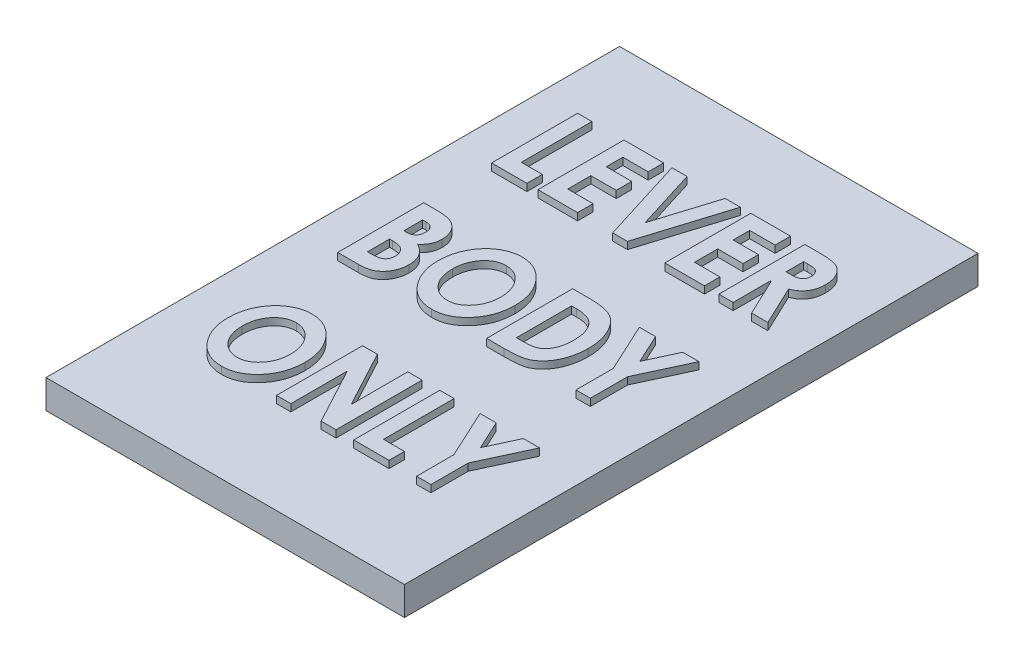
from build123d import *

# Parameters (mm, degrees)
SKETCH1_W           = 19.4
SKETCH1_H           = 34.4
BOSS_EXTRUDE1_DEPTH = 2
SKETCH2_W           = 25
SKETCH2_H           = 40
BOSS_EXTRUDE2_DEPTH = 2
BOSS_EXTRUDE3_DEPTH = 0.5


with BuildPart() as part:
    # Sketch1 → Boss-Extrude1 (new body)
    with BuildSketch(Plane(origin=(0, 0, 0), x_dir=(1, 0, 0), z_dir=(0, 1, 0))):
        Rectangle(SKETCH1_W, SKETCH1_H)
    extrude(amount=BOSS_EXTRUDE1_DEPTH)

    # Sketch2 → Boss-Extrude2 (add)
    with BuildSketch(Plane(origin=(0, 2, 0), x_dir=(1, 0, 0), z_dir=(0, 1, 0))):
        Rectangle(SKETCH2_W, SKETCH2_H)
    extrude(amount=BOSS_EXTRUDE2_DEPTH)

    # Sketch3 → Boss-Extrude3 (add)
    with BuildSketch(Plane(origin=(0, 4, 0), x_dir=(1, 0, 0), z_dir=(0, 1, 0))):
        Polygon((-9.423076923, 14), (-8.423076923, 14), (-8.423076923, 9.076923077), (-6.961538462, 9.076923077), (-6.961538462, 8), (-9.423076923, 8), align=None)
        Polygon((-6.192307692, 14), (-3.423076923, 14), (-3.423076923, 12.923076923), (-5.192307692, 12.923076923), (-5.192307692, 11.769230769), (-3.423076923, 11.769230769), (-3.423076923, 10.692307692), (-5.192307692, 10.692307692), (-5.192307692, 9.076923077), (-3.423076923, 9.076923077), (-3.423076923, 8), (-6.192307692, 8), align=None)
        Polygon((-2.846153846, 14), (-1.788461538, 14), (-0.461538462, 9.737980769), (0.867788462, 14), (1.923076923, 14), (0.051682692, 8), (-0.977163462, 8), align=None)
        Polygon((2.653846154, 14), (5.423076923, 14), (5.423076923, 12.923076923), (3.653846154, 12.923076923), (3.653846154, 11.769230769), (5.423076923, 11.769230769), (5.423076923, 10.692307692), (3.653846154, 10.692307692), (3.653846154, 9.076923077), (5.423076923, 9.076923077), (5.423076923, 8), (2.653846154, 8), align=None)
        with BuildLine():
            Line((6.423076923, 14), (7.495192308, 14))
            add(Edge.make_bspline(
                [(7.495192308, 14), (7.565716082, 13.999692793), (7.702010779, 13.999099082), (7.898391471, 13.990259019), (8.079272988, 13.977728257), (8.244156273, 13.958758313), (8.393014185, 13.933838236), (8.526193833, 13.903624533), (8.644139743, 13.87011321), (8.779050299, 13.815187629), (8.930257846, 13.729159202), (9.092102694, 13.597787753), (9.233816486, 13.436238489), (9.355507645, 13.248692243), (9.455996707, 13.038283275), (9.526259048, 12.806550176), (9.56898116, 12.556866273), (9.574225501, 12.384390756), (9.576923077, 12.295673077)],
                knots=[0, 0, 0, 0, 0.000211552, 0.000408847, 0.00058962, 0.000755402, 0.000906563, 0.001042146, 0.001164983, 0.001273902, 0.001478441, 0.001684363, 0.001896369, 0.002120391, 0.002353186, 0.002593456, 0.002844601, 0.003110617, 0.003110617, 0.003110617, 0.003110617], degree=3))
            add(Edge.make_bspline(
                [(9.576923077, 12.295673077), (9.57634034, 12.248372382), (9.575197559, 12.155612924), (9.562997288, 12.019467998), (9.542424057, 11.889473187), (9.514918602, 11.764865894), (9.479415699, 11.64605475), (9.433945253, 11.533657974), (9.383200458, 11.42639336), (9.322007668, 11.325942603), (9.254082633, 11.231148047), (9.177195351, 11.142737763), (9.093581116, 11.059422992), (8.999749925, 10.983791093), (8.898931748, 10.912490949), (8.789272857, 10.848096085), (8.672313049, 10.788408867), (8.590015205, 10.755003739), (8.548076923, 10.737980769)],
                knots=[0, 0, 0, 0, 0.000141873, 0.000278221, 0.000409627, 0.000536474, 0.000660808, 0.000781108, 0.00089991, 0.001016373, 0.00113346, 0.001249357, 0.001367494, 0.001487072, 0.001610449, 0.001737632, 0.001868249, 0.002003976, 0.002003976, 0.002003976, 0.002003976], degree=3))
            Line((8.548076923, 10.737980769), (9.846153846, 8))
            Line((9.846153846, 8), (8.710336538, 8))
            Line((8.710336538, 8), (7.469951923, 10.615384615))
            Line((7.469951923, 10.615384615), (7.423076923, 10.615384615))
            Line((7.423076923, 10.615384615), (7.423076923, 8))
            Line((7.423076923, 8), (6.423076923, 8))
            Line((6.423076923, 8), (6.423076923, 14))
        make_face()
        with BuildLine():
            Line((7.423076923, 11.692307692), (7.737980769, 11.692307692))
            add(Edge.make_bspline(
                [(7.737980769, 11.692307692), (7.776444427, 11.692888957), (7.850215642, 11.69400379), (7.95624872, 11.699097626), (8.052470782, 11.711523783), (8.139483597, 11.727213836), (8.218081269, 11.745218745), (8.286524629, 11.771018343), (8.346488021, 11.799230102), (8.41266021, 11.84465353), (8.481983468, 11.916603886), (8.538731233, 12.028063417), (8.572097584, 12.161949108), (8.575245837, 12.258603368), (8.576923077, 12.310096154)],
                knots=[0, 0, 0, 0, 0.00011541, 0.000221349, 0.000318252, 0.000406189, 0.000486646, 0.000559658, 0.000625237, 0.000684911, 0.000799674, 0.000920645, 0.001055908, 0.001210134, 0.001210134, 0.001210134, 0.001210134], degree=3))
            add(Edge.make_bspline(
                [(8.576923077, 12.310096154), (8.575743875, 12.341827369), (8.573442756, 12.403748342), (8.556284171, 12.493096474), (8.528812603, 12.576443972), (8.488732703, 12.651576163), (8.440824607, 12.719628017), (8.38404366, 12.777722916), (8.3195226, 12.825220132), (8.244050024, 12.863789384), (8.148509814, 12.891389305), (8.025928454, 12.910559882), (7.87239739, 12.921700941), (7.759634934, 12.92259225), (7.698317308, 12.923076923)],
                knots=[0, 0, 0, 0, 9.5142e-05, 0.000185662, 0.000271941, 0.000357422, 0.000440136, 0.00052088, 0.00059997, 0.000679524, 0.000773812, 0.000896914, 0.001051229, 0.001235158, 0.001235158, 0.001235158, 0.001235158], degree=3))
            Line((7.698317308, 12.923076923), (7.423076923, 12.923076923))
            Line((7.423076923, 12.923076923), (7.423076923, 11.692307692))
        make_face(mode=Mode.SUBTRACT)
        with BuildLine():
            Line((-9.384615385, -2.769230769), (-9.384615385, 3.230769231))
            Line((-9.384615385, 3.230769231), (-8.575721154, 3.230769231))
            add(Edge.make_bspline(
                [(-8.575721154, 3.230769231), (-8.519223397, 3.230779244), (-8.409797524, 3.230798639), (-8.251527984, 3.224137387), (-8.1048841, 3.21575209), (-7.970014332, 3.206007352), (-7.847487459, 3.189714384), (-7.736666137, 3.172301881), (-7.637370877, 3.151126425), (-7.576018233, 3.13259888), (-7.546875, 3.123798077)],
                knots=[0, 0, 0, 0, 0.000169475, 0.000328243, 0.000475119, 0.000610168, 0.000733756, 0.000845793, 0.000946697, 0.001037996, 0.001037996, 0.001037996, 0.001037996], degree=3))
            add(Edge.make_bspline(
                [(-7.546875, 3.123798077), (-7.50895312, 3.111263932), (-7.433889188, 3.086453395), (-7.326939058, 3.037596266), (-7.225590471, 2.982344728), (-7.129952113, 2.91969153), (-7.040650895, 2.848451795), (-6.957806657, 2.76882825), (-6.880642941, 2.682016213), (-6.809888719, 2.588393857), (-6.746163543, 2.488843349), (-6.691041525, 2.384164115), (-6.643730514, 2.27538287), (-6.605222336, 2.161999231), (-6.575442917, 2.044201303), (-6.55329253, 1.922185523), (-6.541792023, 1.795492904), (-6.539584043, 1.709554987), (-6.538461538, 1.665865385)],
                knots=[0, 0, 0, 0, 0.000119741, 0.000237019, 0.000352128, 0.000465803, 0.000579555, 0.000694318, 0.000810103, 0.000927652, 0.001046015, 0.0011643, 0.001282192, 0.00140154, 0.001523101, 0.001646408, 0.001773181, 0.001904279, 0.001904279, 0.001904279, 0.001904279], degree=3))
            add(Edge.make_bspline(
                [(-6.538461538, 1.665865385), (-6.54014369, 1.609696432), (-6.543451703, 1.499238068), (-6.567568843, 1.337455146), (-6.608999868, 1.183701436), (-6.665359697, 1.036786187), (-6.741253748, 0.895929761), (-6.83855043, 0.761798645), (-6.954664737, 0.630153137), (-7.044734275, 0.550721859), (-7.091346154, 0.509615385)],
                knots=[0, 0, 0, 0, 0.000168479, 0.000331321, 0.000489341, 0.00064536, 0.000802389, 0.000967818, 0.001141495, 0.001327778, 0.001327778, 0.001327778, 0.001327778], degree=3))
            add(Edge.make_bspline(
                [(-7.091346154, 0.509615385), (-7.051817001, 0.488039316), (-6.974329897, 0.445744783), (-6.864843951, 0.375730957), (-6.763143382, 0.30209537), (-6.669513415, 0.224658462), (-6.585120992, 0.141952308), (-6.50742828, 0.056843737), (-6.439049013, -0.033518199), (-6.35862584, -0.159121332), (-6.275357097, -0.328043204), (-6.204521409, -0.547378676), (-6.161764955, -0.784402781), (-6.156537908, -0.948135201), (-6.153846154, -1.032451923)],
                knots=[0, 0, 0, 0, 0.000135071, 0.000264773, 0.000389547, 0.000511582, 0.000628879, 0.000743768, 0.000856992, 0.00096835, 0.001190884, 0.001419698, 0.001657818, 0.001910634, 0.001910634, 0.001910634, 0.001910634], degree=3))
            add(Edge.make_bspline(
                [(-6.153846154, -1.032451923), (-6.156594668, -1.114374148), (-6.162007816, -1.275718466), (-6.205603009, -1.511862417), (-6.274976299, -1.737619757), (-6.373689267, -1.948466839), (-6.492493121, -2.141473397), (-6.630267328, -2.310195479), (-6.784600771, -2.453005097), (-6.927536116, -2.550326258), (-7.051341578, -2.615741234), (-7.154037336, -2.655032792), (-7.263266757, -2.692615296), (-7.382457851, -2.718769322), (-7.508966525, -2.742305299), (-7.644750132, -2.757242352), (-7.788316244, -2.767039015), (-7.887001552, -2.768488864), (-7.9375, -2.769230769)],
                knots=[0, 0, 0, 0, 0.000245616, 0.000483736, 0.000717911, 0.000952372, 0.001180171, 0.00139624, 0.001603786, 0.001808809, 0.001913099, 0.002023133, 0.002138298, 0.002259287, 0.002388721, 0.00252424, 0.002668791, 0.002820277, 0.002820277, 0.002820277, 0.002820277], degree=3))
            Line((-7.9375, -2.769230769), (-9.384615385, -2.769230769))
        make_face()
        with BuildLine():
            Line((-8.384615385, 2.153846154), (-8.384615385, 0.846153846))
            Line((-8.384615385, 0.846153846), (-8.1875, 0.846153846))
            add(Edge.make_bspline(
                [(-8.1875, 0.846153846), (-8.135970161, 0.847719424), (-8.038368132, 0.850684766), (-7.902730464, 0.886293702), (-7.786785678, 0.94260981), (-7.694575497, 1.024731845), (-7.624115694, 1.125730918), (-7.573233379, 1.24335541), (-7.543074265, 1.377507101), (-7.540043851, 1.472194289), (-7.538461538, 1.521634615)],
                knots=[0, 0, 0, 0, 0.000154226, 0.000292118, 0.00041736, 0.000537438, 0.000658158, 0.000784102, 0.000919685, 0.001067834, 0.001067834, 0.001067834, 0.001067834], degree=3))
            add(Edge.make_bspline(
                [(-7.538461538, 1.521634615), (-7.540052556, 1.56789856), (-7.543089778, 1.656215571), (-7.57299262, 1.780890624), (-7.619188768, 1.891842809), (-7.687807945, 1.985656031), (-7.775113175, 2.062884387), (-7.883771389, 2.117442112), (-8.012347939, 2.148305748), (-8.103989639, 2.151924748), (-8.152644231, 2.153846154)],
                knots=[0, 0, 0, 0, 0.000138555, 0.000264499, 0.000382392, 0.000496827, 0.000610121, 0.000728917, 0.000857764, 0.001003598, 0.001003598, 0.001003598, 0.001003598], degree=3))
            Line((-8.152644231, 2.153846154), (-8.384615385, 2.153846154))
        make_face(mode=Mode.SUBTRACT)
        with BuildLine():
            Line((-8.384615385, -0.153846154), (-8.384615385, -1.692307692))
            Line((-8.384615385, -1.692307692), (-8.149038462, -1.692307692))
            add(Edge.make_bspline(
                [(-8.149038462, -1.692307692), (-8.102152584, -1.691956339), (-8.011902957, -1.691280027), (-7.882664911, -1.683138923), (-7.765564262, -1.668551254), (-7.660521927, -1.650061426), (-7.567112784, -1.624886702), (-7.485660793, -1.594120202), (-7.415518355, -1.55832623), (-7.340143284, -1.501796888), (-7.264139712, -1.415306015), (-7.198036828, -1.291730914), (-7.161056072, -1.146693885), (-7.156332131, -1.044280006), (-7.153846154, -0.990384615)],
                knots=[0, 0, 0, 0, 0.000140646, 0.000270726, 0.000388201, 0.000494522, 0.00059045, 0.000677951, 0.000755371, 0.000825804, 0.000959455, 0.001097111, 0.001242588, 0.001404188, 0.001404188, 0.001404188, 0.001404188], degree=3))
            add(Edge.make_bspline(
                [(-7.153846154, -0.990384615), (-7.154522301, -0.95870714), (-7.155836009, -0.897159971), (-7.166501756, -0.807286972), (-7.186032168, -0.722879066), (-7.212126436, -0.64337779), (-7.246194974, -0.56930711), (-7.287286468, -0.500406649), (-7.335682454, -0.435985363), (-7.392431253, -0.376933657), (-7.457758736, -0.323347643), (-7.533147443, -0.277703731), (-7.618221654, -0.238872555), (-7.713680672, -0.208579186), (-7.818294802, -0.182607853), (-7.933141109, -0.167110862), (-8.057456704, -0.15554585), (-8.143798234, -0.154427681), (-8.188701923, -0.153846154)],
                knots=[0, 0, 0, 0, 9.502e-05, 0.000184618, 0.000270923, 0.00035454, 0.000435213, 0.000514984, 0.000594793, 0.000676399, 0.000760121, 0.000847523, 0.000940032, 0.001039994, 0.001147565, 0.001262981, 0.001387251, 0.001521914, 0.001521914, 0.001521914, 0.001521914], degree=3))
            Line((-8.188701923, -0.153846154), (-8.384615385, -0.153846154))
        make_face(mode=Mode.SUBTRACT)
        with BuildLine():
            add(Edge.make_bspline(
                [(-2.681490385, 3.384615385), (-2.591164255, 3.381950448), (-2.413053702, 3.376695563), (-2.150935296, 3.331641838), (-1.898422683, 3.259621782), (-1.655432938, 3.158133184), (-1.423023311, 3.026463346), (-1.199831022, 2.867405077), (-0.987681743, 2.677594102), (-0.786611524, 2.463531782), (-0.602747581, 2.228210672), (-0.440912701, 1.977818944), (-0.304958626, 1.71427333), (-0.191677454, 1.439295165), (-0.107377357, 1.150012365), (-0.044505324, 0.849166271), (-0.006361322, 0.535035636), (-0.002145075, 0.321420219), (0, 0.212740385)],
                knots=[0, 0, 0, 0, 0.000270817, 0.000534013, 0.000795362, 0.001057196, 0.001321969, 0.001595123, 0.001877797, 0.002174555, 0.002475096, 0.002772484, 0.003067612, 0.003363571, 0.003663238, 0.00397015, 0.004284863, 0.004610806, 0.004610806, 0.004610806, 0.004610806], degree=3))
            add(Edge.make_bspline(
                [(0, 0.212740385), (-0.002088915, 0.105247644), (-0.006201855, -0.106398751), (-0.045221542, -0.416976174), (-0.104295057, -0.715660813), (-0.189739524, -1.001531272), (-0.301208269, -1.27440565), (-0.435916328, -1.535008127), (-0.595885479, -1.78241769), (-0.776594377, -2.015165241), (-0.976141215, -2.226057211), (-1.186616561, -2.413170521), (-1.409169908, -2.569987921), (-1.641058163, -2.700240621), (-1.884402526, -2.800689766), (-2.138549561, -2.87168519), (-2.403181874, -2.914722806), (-2.583173366, -2.920269419), (-2.674278846, -2.923076923)],
                knots=[0, 0, 0, 0, 0.00032234, 0.000634666, 0.000937563, 0.001234926, 0.001528205, 0.001820646, 0.002113701, 0.002410868, 0.002703353, 0.002983535, 0.003254317, 0.003518502, 0.003779876, 0.004042052, 0.004308614, 0.004581831, 0.004581831, 0.004581831, 0.004581831], degree=3))
            add(Edge.make_bspline(
                [(-2.674278846, -2.923076923), (-2.769832133, -2.920581663), (-2.957607937, -2.915678122), (-3.232216693, -2.868746866), (-3.495578733, -2.798016906), (-3.744950499, -2.692976314), (-3.983023867, -2.56133545), (-4.207324744, -2.398616705), (-4.419629753, -2.207360087), (-4.61740351, -1.990106351), (-4.795603935, -1.752072268), (-4.954734891, -1.501842605), (-5.086628681, -1.23881097), (-5.195469629, -0.965337827), (-5.281246432, -0.681596897), (-5.340894687, -0.386229456), (-5.377967896, -0.08027681), (-5.382378521, 0.127697972), (-5.384615385, 0.233173077)],
                knots=[0, 0, 0, 0, 0.000286421, 0.000562858, 0.000833462, 0.001102878, 0.001372433, 0.001647964, 0.001932239, 0.002228312, 0.002527832, 0.002823283, 0.003116769, 0.00340915, 0.003705363, 0.004004726, 0.004312136, 0.004628471, 0.004628471, 0.004628471, 0.004628471], degree=3))
            add(Edge.make_bspline(
                [(-5.384615385, 0.233173077), (-5.383397255, 0.30412125), (-5.380978251, 0.445012578), (-5.363559938, 0.654028624), (-5.336563491, 0.858839828), (-5.296284183, 1.058936932), (-5.246020956, 1.254824212), (-5.184646307, 1.446827975), (-5.111243652, 1.634154789), (-5.026883646, 1.816481702), (-4.934554703, 1.992797911), (-4.829887388, 2.158617406), (-4.7198769, 2.316739867), (-4.600523611, 2.464855439), (-4.472485383, 2.603826429), (-4.336040378, 2.733242875), (-4.190674232, 2.852797057), (-4.038645393, 2.962905002), (-3.881121848, 3.062968203), (-3.717969059, 3.147598125), (-3.553359515, 3.222401666), (-3.38430353, 3.280245886), (-3.213302631, 3.328610358), (-3.038508742, 3.359704127), (-2.861149416, 3.381937947), (-2.741657833, 3.383718716), (-2.681490385, 3.384615385)],
                knots=[0, 0, 0, 0, 0.000212825, 0.000422636, 0.000628824, 0.000832248, 0.00103456, 0.001235256, 0.001436581, 0.001637716, 0.00183773, 0.002033168, 0.002225569, 0.002415344, 0.002603324, 0.002792069, 0.002979048, 0.003167535, 0.003354947, 0.003538278, 0.003718527, 0.003896805, 0.004073798, 0.004251072, 0.004428933, 0.004609321, 0.004609321, 0.004609321, 0.004609321], degree=3))
        make_face()
        with BuildLine():
            add(Edge.make_bspline(
                [(-2.695913462, 2.307692308), (-2.75452499, 2.305834514), (-2.870007443, 2.302174097), (-3.039283894, 2.273466331), (-3.20151597, 2.228568585), (-3.355706089, 2.161807002), (-3.503771585, 2.079355677), (-3.64442309, 1.977129802), (-3.776716275, 1.855993105), (-3.900931391, 1.718260122), (-4.014467278, 1.566873194), (-4.113601374, 1.403295329), (-4.197576612, 1.23024597), (-4.266814261, 1.047323784), (-4.319241261, 0.853976084), (-4.357515284, 0.651074609), (-4.380988101, 0.438052793), (-4.383388449, 0.2929296), (-4.384615385, 0.21875)],
                knots=[0, 0, 0, 0, 0.000175744, 0.000346269, 0.000513677, 0.000679547, 0.000849057, 0.001021196, 0.001199875, 0.001386235, 0.00157686, 0.001766707, 0.00195915, 0.00215314, 0.002352587, 0.002559321, 0.002772089, 0.002994562, 0.002994562, 0.002994562, 0.002994562], degree=3))
            add(Edge.make_bspline(
                [(-4.384615385, 0.21875), (-4.382848022, 0.136530174), (-4.379388111, -0.024428948), (-4.350074025, -0.258969355), (-4.30251585, -0.480508231), (-4.234317519, -0.688288922), (-4.150087364, -0.88446937), (-4.042530646, -1.065108406), (-3.919200163, -1.234959431), (-3.821053231, -1.334496708), (-3.771634615, -1.384615385)],
                knots=[0, 0, 0, 0, 0.000246582, 0.000482725, 0.00070787, 0.000925282, 0.001137873, 0.001346897, 0.001554833, 0.001765715, 0.001765715, 0.001765715, 0.001765715], degree=3))
            add(Edge.make_bspline(
                [(-3.771634615, -1.384615385), (-3.731837841, -1.421463544), (-3.653562156, -1.493939642), (-3.526612245, -1.587353146), (-3.396276722, -1.667705174), (-3.260952816, -1.732953736), (-3.121161001, -1.783563638), (-2.97703852, -1.819784526), (-2.828822436, -1.842065954), (-2.728442066, -1.844784584), (-2.677884615, -1.846153846)],
                knots=[0, 0, 0, 0, 0.000162598, 0.000319811, 0.000471938, 0.000621383, 0.000769664, 0.000917168, 0.001066579, 0.001218193, 0.001218193, 0.001218193, 0.001218193], degree=3))
            add(Edge.make_bspline(
                [(-2.677884615, -1.846153846), (-2.620885262, -1.844245159), (-2.508212271, -1.840472179), (-2.342268753, -1.812214094), (-2.183016444, -1.765133757), (-2.029993616, -1.69961398), (-1.883813441, -1.615024297), (-1.745177404, -1.510334429), (-1.612583561, -1.388162178), (-1.487284322, -1.249529618), (-1.372515629, -1.096951333), (-1.273069628, -0.933153092), (-1.187772272, -0.761321431), (-1.119851565, -0.5802274), (-1.065042059, -0.390695041), (-1.02731772, -0.192322527), (-1.003616847, 0.014644912), (-1.001221641, 0.155382335), (-1, 0.227163462)],
                knots=[0, 0, 0, 0, 0.000170944, 0.000337912, 0.000503345, 0.00066811, 0.000836125, 0.001008722, 0.001188211, 0.001376269, 0.001568577, 0.001760075, 0.001950359, 0.002143225, 0.002339526, 0.002541538, 0.002748332, 0.002963597, 0.002963597, 0.002963597, 0.002963597], degree=3))
            add(Edge.make_bspline(
                [(-1, 0.227163462), (-1.001105024, 0.298556519), (-1.003278245, 0.438963358), (-1.028748392, 0.644997304), (-1.0664444, 0.842942952), (-1.120638738, 1.032478462), (-1.190901893, 1.213154832), (-1.274756083, 1.386500691), (-1.376722309, 1.549839608), (-1.491105558, 1.704321996), (-1.617047299, 1.844833153), (-1.751263235, 1.96814392), (-1.890660109, 2.074335652), (-2.03900953, 2.158822306), (-2.19380645, 2.225419685), (-2.355330999, 2.274048129), (-2.523872091, 2.301928637), (-2.638121272, 2.305756174), (-2.695913462, 2.307692308)],
                knots=[0, 0, 0, 0, 0.000214064, 0.000420994, 0.000621826, 0.000818127, 0.001011423, 0.001202786, 0.001394913, 0.001588184, 0.001778832, 0.001960019, 0.002134298, 0.002303355, 0.002470803, 0.002638883, 0.002808222, 0.002981566, 0.002981566, 0.002981566, 0.002981566], degree=3))
        make_face(mode=Mode.SUBTRACT)
        with BuildLine():
            Line((1, 3.230769231), (2.181490385, 3.230769231))
            add(Edge.make_bspline(
                [(2.181490385, 3.230769231), (2.273662624, 3.230018527), (2.452140179, 3.228564904), (2.710393115, 3.212571589), (2.950653338, 3.187617422), (3.172775389, 3.153620317), (3.376600674, 3.108521827), (3.561638159, 3.05160638), (3.728999806, 2.986467723), (3.880031096, 2.909529867), (4.017349051, 2.819759858), (4.147970469, 2.719779993), (4.271681185, 2.606635016), (4.388706925, 2.480272395), (4.500930858, 2.342416004), (4.604733453, 2.18979083), (4.704961156, 2.026743274), (4.797156201, 1.851227775), (4.880823071, 1.665888942), (4.954755281, 1.471876669), (5.015462019, 1.269605012), (5.066095374, 1.059771897), (5.105913195, 0.842333654), (5.132906697, 0.617126484), (5.150311385, 0.384488016), (5.152654886, 0.226794608), (5.153846154, 0.146634615)],
                knots=[0, 0, 0, 0, 0.000276484, 0.00053537, 0.00077588, 0.001000951, 0.001209148, 0.001401523, 0.001581194, 0.001747294, 0.001908987, 0.002072701, 0.002240303, 0.002411234, 0.002588997, 0.002773032, 0.002964531, 0.003162921, 0.003367336, 0.00357427, 0.003785292, 0.004000433, 0.004221567, 0.00444802, 0.004680601, 0.004921061, 0.004921061, 0.004921061, 0.004921061], degree=3))
            add(Edge.make_bspline(
                [(5.153846154, 0.146634615), (5.151858115, 0.0335282), (5.14794752, -0.188959076), (5.107595895, -0.515181604), (5.046576806, -0.828522164), (4.956701758, -1.12497884), (4.849292817, -1.403902526), (4.718727466, -1.65833924), (4.570766889, -1.889446894), (4.402666348, -2.092582074), (4.222578494, -2.269348115), (4.034564982, -2.419299158), (3.837412, -2.538191847), (3.663126617, -2.613768166), (3.512198318, -2.660756161), (3.380002074, -2.688298026), (3.229732437, -2.713866892), (3.059947294, -2.733240761), (2.871672849, -2.750750502), (2.664333302, -2.760272298), (2.438361617, -2.768142464), (2.281258764, -2.768858316), (2.199519231, -2.769230769)],
                knots=[0, 0, 0, 0, 0.000339155, 0.000667139, 0.00098465, 0.001295713, 0.001595243, 0.001880139, 0.002152181, 0.002416877, 0.002669306, 0.002908078, 0.003136674, 0.003357939, 0.003476174, 0.003610322, 0.003762668, 0.003933366, 0.004122817, 0.00432983, 0.004555907, 0.004801111, 0.004801111, 0.004801111, 0.004801111], degree=3))
            Line((2.199519231, -2.769230769), (1, -2.769230769))
            Line((1, -2.769230769), (1, 3.230769231))
        make_face()
        with BuildLine():
            Line((2, 2.153846154), (2, -1.692307692))
            Line((2, -1.692307692), (2.462740385, -1.692307692))
            add(Edge.make_bspline(
                [(2.462740385, -1.692307692), (2.517653835, -1.692166734), (2.623967915, -1.691893834), (2.777362761, -1.680756617), (2.919664819, -1.669431542), (3.049398849, -1.647969499), (3.168061034, -1.624329888), (3.273752663, -1.590478331), (3.369877214, -1.556115388), (3.481114883, -1.497199737), (3.607248397, -1.404370036), (3.741252593, -1.263984054), (3.861057484, -1.092879835), (3.964545896, -0.891987897), (4.049849511, -0.663479533), (4.110131458, -0.408786759), (4.148024536, -0.12974435), (4.151855283, 0.064773085), (4.153846154, 0.165865385)],
                knots=[0, 0, 0, 0, 0.000164681, 0.000318827, 0.000461269, 0.000592675, 0.000713138, 0.000823773, 0.000925341, 0.001018883, 0.001200389, 0.001392494, 0.001598584, 0.00182491, 0.002068699, 0.00232844, 0.002608573, 0.002911696, 0.002911696, 0.002911696, 0.002911696], degree=3))
            add(Edge.make_bspline(
                [(4.153846154, 0.165865385), (4.152495136, 0.244435082), (4.1498635, 0.397480266), (4.128484793, 0.620607744), (4.090697103, 0.830097192), (4.041527867, 1.026945632), (3.974799673, 1.208921856), (3.895097129, 1.377890486), (3.801027416, 1.533966995), (3.725085083, 1.627022337), (3.6875, 1.673076923)],
                knots=[0, 0, 0, 0, 0.000235687, 0.000459093, 0.000671521, 0.000873833, 0.001066988, 0.001251932, 0.001433745, 0.001611897, 0.001611897, 0.001611897, 0.001611897], degree=3))
            add(Edge.make_bspline(
                [(3.6875, 1.673076923), (3.650898549, 1.711890109), (3.57734728, 1.789885899), (3.445929742, 1.887300419), (3.29996862, 1.970703331), (3.137291035, 2.037553341), (2.959811246, 2.090721696), (2.766409422, 2.126870944), (2.557477297, 2.150488949), (2.412730346, 2.152700435), (2.337740385, 2.153846154)],
                knots=[0, 0, 0, 0, 0.000159779, 0.000321079, 0.000488496, 0.000663052, 0.00084748, 0.001043364, 0.001252547, 0.001477422, 0.001477422, 0.001477422, 0.001477422], degree=3))
            Line((2.337740385, 2.153846154), (2, 2.153846154))
        make_face(mode=Mode.SUBTRACT)
        Polygon((5.653846154, 3.230769231), (6.782451923, 3.230769231), (7.730769231, 1.1875), (8.677884615, 3.230769231), (9.807692308, 3.230769231), (8.230769231, -0.170673077), (8.230769231, -2.769230769), (7.230769231, -2.769230769), (7.230769231, -0.170673077), align=None)
        with BuildLine():
            add(Edge.make_bspline(
                [(-6.566105769, -7.384615385), (-6.475779639, -7.387280322), (-6.297669086, -7.392535206), (-6.03555068, -7.437588931), (-5.783038067, -7.509608987), (-5.540048322, -7.611097585), (-5.307638695, -7.742767423), (-5.084446406, -7.901825692), (-4.872297127, -8.091636667), (-4.671226909, -8.305698987), (-4.487362966, -8.541020097), (-4.325528086, -8.791411825), (-4.189574011, -9.05495744), (-4.076292839, -9.329935604), (-3.991992742, -9.619218405), (-3.929120708, -9.920064498), (-3.890976707, -10.234195133), (-3.886760459, -10.44781055), (-3.884615385, -10.556490385)],
                knots=[0, 0, 0, 0, 0.000270817, 0.000534013, 0.000795362, 0.001057196, 0.001321969, 0.001595123, 0.001877797, 0.002174555, 0.002475096, 0.002772484, 0.003067612, 0.003363571, 0.003663238, 0.00397015, 0.004284863, 0.004610806, 0.004610806, 0.004610806, 0.004610806], degree=3))
            add(Edge.make_bspline(
                [(-3.884615385, -10.556490385), (-3.886704299, -10.663983125), (-3.89081724, -10.87562952), (-3.929836927, -11.186206943), (-3.988910442, -11.484891582), (-4.074354909, -11.770762041), (-4.185823654, -12.043636419), (-4.320531712, -12.304238896), (-4.480500864, -12.55164846), (-4.661209762, -12.78439601), (-4.8607566, -12.995287981), (-5.071231945, -13.18240129), (-5.293785292, -13.33921869), (-5.525673548, -13.46947139), (-5.76901791, -13.569920535), (-6.023164945, -13.64091596), (-6.287797259, -13.683953575), (-6.46778875, -13.689500188), (-6.558894231, -13.692307692)],
                knots=[0, 0, 0, 0, 0.00032234, 0.000634666, 0.000937563, 0.001234926, 0.001528205, 0.001820646, 0.002113701, 0.002410868, 0.002703353, 0.002983535, 0.003254317, 0.003518502, 0.003779876, 0.004042052, 0.004308614, 0.004581831, 0.004581831, 0.004581831, 0.004581831], degree=3))
            add(Edge.make_bspline(
                [(-6.558894231, -13.692307692), (-6.654447518, -13.689812432), (-6.842223322, -13.684908892), (-7.116832078, -13.637977635), (-7.380194118, -13.567247676), (-7.629565883, -13.462207083), (-7.867639251, -13.330566219), (-8.091940129, -13.167847474), (-8.304245137, -12.976590856), (-8.502018894, -12.759337121), (-8.68021932, -12.521303037), (-8.839350275, -12.271073374), (-8.971244066, -12.008041739), (-9.080085014, -11.734568596), (-9.165861817, -11.450827666), (-9.225510071, -11.155460225), (-9.262583281, -10.849507579), (-9.266993906, -10.641532797), (-9.269230769, -10.536057692)],
                knots=[0, 0, 0, 0, 0.000286421, 0.000562858, 0.000833462, 0.001102878, 0.001372433, 0.001647964, 0.001932239, 0.002228312, 0.002527832, 0.002823283, 0.003116769, 0.00340915, 0.003705363, 0.004004726, 0.004312136, 0.004628471, 0.004628471, 0.004628471, 0.004628471], degree=3))
            add(Edge.make_bspline(
                [(-9.269230769, -10.536057692), (-9.26801264, -10.465109519), (-9.265593636, -10.324218191), (-9.248175323, -10.115202145), (-9.221178876, -9.910390942), (-9.180899568, -9.710293837), (-9.130636341, -9.514406557), (-9.069261691, -9.322402794), (-8.995859037, -9.13507598), (-8.911499031, -8.952749067), (-8.819170087, -8.776432858), (-8.714502773, -8.610613363), (-8.604492285, -8.452490902), (-8.485138995, -8.304375331), (-8.357100768, -8.16540434), (-8.220655763, -8.035987894), (-8.075289616, -7.916433712), (-7.923260778, -7.806325767), (-7.765737233, -7.706262566), (-7.602584443, -7.621632644), (-7.4379749, -7.546829104), (-7.268918915, -7.488984884), (-7.097918016, -7.440620411), (-6.923124127, -7.409526642), (-6.745764801, -7.387292822), (-6.626273217, -7.385512053), (-6.566105769, -7.384615385)],
                knots=[0, 0, 0, 0, 0.000212825, 0.000422636, 0.000628824, 0.000832248, 0.00103456, 0.001235256, 0.001436581, 0.001637716, 0.00183773, 0.002033168, 0.002225569, 0.002415344, 0.002603324, 0.002792069, 0.002979048, 0.003167535, 0.003354947, 0.003538278, 0.003718527, 0.003896805, 0.004073798, 0.004251072, 0.004428933, 0.004609321, 0.004609321, 0.004609321, 0.004609321], degree=3))
        make_face()
        with BuildLine():
            add(Edge.make_bspline(
                [(-6.580528846, -8.461538462), (-6.639140374, -8.463396255), (-6.754622827, -8.467056672), (-6.923899279, -8.495764438), (-7.086131354, -8.540662184), (-7.240321474, -8.607423768), (-7.388386969, -8.689875092), (-7.529038475, -8.792100967), (-7.66133166, -8.913237664), (-7.785546776, -9.050970647), (-7.899082663, -9.202357575), (-7.998216759, -9.36593544), (-8.082191996, -9.538984799), (-8.151429645, -9.721906985), (-8.203856646, -9.915254685), (-8.242130669, -10.118156161), (-8.265603486, -10.331177977), (-8.268003834, -10.476301169), (-8.269230769, -10.550480769)],
                knots=[0, 0, 0, 0, 0.000175744, 0.000346269, 0.000513677, 0.000679547, 0.000849057, 0.001021196, 0.001199875, 0.001386235, 0.00157686, 0.001766707, 0.00195915, 0.00215314, 0.002352587, 0.002559321, 0.002772089, 0.002994562, 0.002994562, 0.002994562, 0.002994562], degree=3))
            add(Edge.make_bspline(
                [(-8.269230769, -10.550480769), (-8.267463406, -10.632700595), (-8.264003496, -10.793659717), (-8.234689409, -11.028200124), (-8.187131235, -11.249739), (-8.118932904, -11.457519691), (-8.034702749, -11.65370014), (-7.92714603, -11.834339175), (-7.803815548, -12.004190201), (-7.705668616, -12.103727477), (-7.65625, -12.153846154)],
                knots=[0, 0, 0, 0, 0.000246582, 0.000482725, 0.00070787, 0.000925282, 0.001137873, 0.001346897, 0.001554833, 0.001765715, 0.001765715, 0.001765715, 0.001765715], degree=3))
            add(Edge.make_bspline(
                [(-7.65625, -12.153846154), (-7.616453226, -12.190694313), (-7.53817754, -12.263170412), (-7.41122763, -12.356583915), (-7.280892106, -12.436935943), (-7.1455682, -12.502184505), (-7.005776385, -12.552794407), (-6.861653905, -12.589015295), (-6.713437821, -12.611296723), (-6.61305745, -12.614015354), (-6.5625, -12.615384615)],
                knots=[0, 0, 0, 0, 0.000162598, 0.000319811, 0.000471938, 0.000621383, 0.000769664, 0.000917168, 0.001066579, 0.001218193, 0.001218193, 0.001218193, 0.001218193], degree=3))
            add(Edge.make_bspline(
                [(-6.5625, -12.615384615), (-6.505500647, -12.613475929), (-6.392827655, -12.609702948), (-6.226884138, -12.581444864), (-6.067631828, -12.534364526), (-5.914609001, -12.468844749), (-5.768428826, -12.384255066), (-5.629792788, -12.279565199), (-5.497198945, -12.157392947), (-5.371899706, -12.018760387), (-5.257131014, -11.866182102), (-5.157685012, -11.702383861), (-5.072387657, -11.530552201), (-5.00446695, -11.349458169), (-4.949657443, -11.159925811), (-4.911933105, -10.961553296), (-4.888232232, -10.754585857), (-4.885837026, -10.613848434), (-4.884615385, -10.542067308)],
                knots=[0, 0, 0, 0, 0.000170944, 0.000337912, 0.000503345, 0.00066811, 0.000836125, 0.001008722, 0.001188211, 0.001376269, 0.001568577, 0.001760075, 0.001950359, 0.002143225, 0.002339526, 0.002541538, 0.002748332, 0.002963597, 0.002963597, 0.002963597, 0.002963597], degree=3))
            add(Edge.make_bspline(
                [(-4.884615385, -10.542067308), (-4.885720408, -10.47067425), (-4.887893629, -10.330267412), (-4.913363777, -10.124233465), (-4.951059784, -9.926287818), (-5.005254122, -9.736752307), (-5.075517278, -9.556075938), (-5.159371467, -9.382730078), (-5.261337693, -9.219391162), (-5.375720943, -9.064908773), (-5.501662684, -8.924397616), (-5.635878619, -8.801086849), (-5.775275494, -8.694895117), (-5.923624914, -8.610408463), (-6.078421835, -8.543811084), (-6.239946383, -8.495182641), (-6.408487476, -8.467302133), (-6.522736657, -8.463474596), (-6.580528846, -8.461538462)],
                knots=[0, 0, 0, 0, 0.000214064, 0.000420994, 0.000621826, 0.000818127, 0.001011423, 0.001202786, 0.001394913, 0.001588184, 0.001778832, 0.001960019, 0.002134298, 0.002303355, 0.002470803, 0.002638883, 0.002808222, 0.002981566, 0.002981566, 0.002981566, 0.002981566], degree=3))
        make_face(mode=Mode.SUBTRACT)
        Polygon((-2.884615385, -7.538461538), (-1.848557692, -7.538461538), (0.269230769, -11.486778846), (0.269230769, -7.538461538), (1.269230769, -7.538461538), (1.269230769, -13.538461538), (0.227163462, -13.538461538), (-1.884615385, -9.602163462), (-1.884615385, -13.538461538), (-2.884615385, -13.538461538), align=None)
        Polygon((2.5, -7.538461538), (3.5, -7.538461538), (3.5, -12.461538462), (4.961538462, -12.461538462), (4.961538462, -13.538461538), (2.5, -13.538461538), align=None)
        Polygon((5.307692308, -7.538461538), (6.436298077, -7.538461538), (7.384615385, -9.581730769), (8.331730769, -7.538461538), (9.461538462, -7.538461538), (7.884615385, -10.939903846), (7.884615385, -13.538461538), (6.884615385, -13.538461538), (6.884615385, -10.939903846), align=None)
    extrude(amount=BOSS_EXTRUDE3_DEPTH)


solid = part.part
